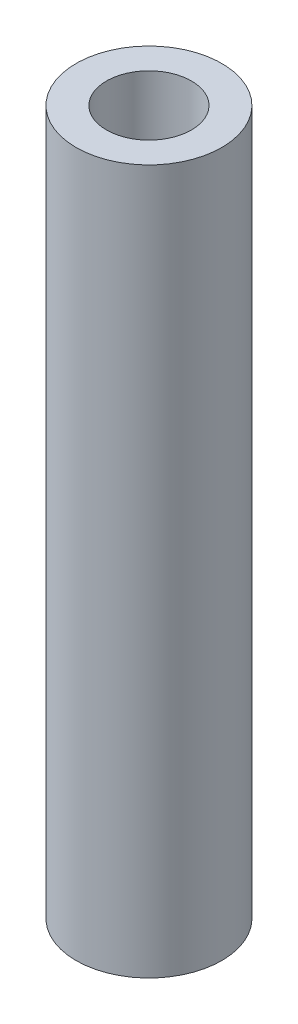
from build123d import *

# Parameters (mm, degrees)
SKETCH1_R           = 3
SKETCH1_R_2         = 1.75
BOSS_EXTRUDE1_DEPTH = 29


with BuildPart() as part:
    # Sketch1 → Boss-Extrude1 (new body)
    with BuildSketch(Plane(origin=(0, 0, 0), x_dir=(1, 0, 0), z_dir=(0, 1, 0))):
        Circle(SKETCH1_R)
        Circle(SKETCH1_R_2, mode=Mode.SUBTRACT)
    extrude(amount=BOSS_EXTRUDE1_DEPTH)


solid = part.part
